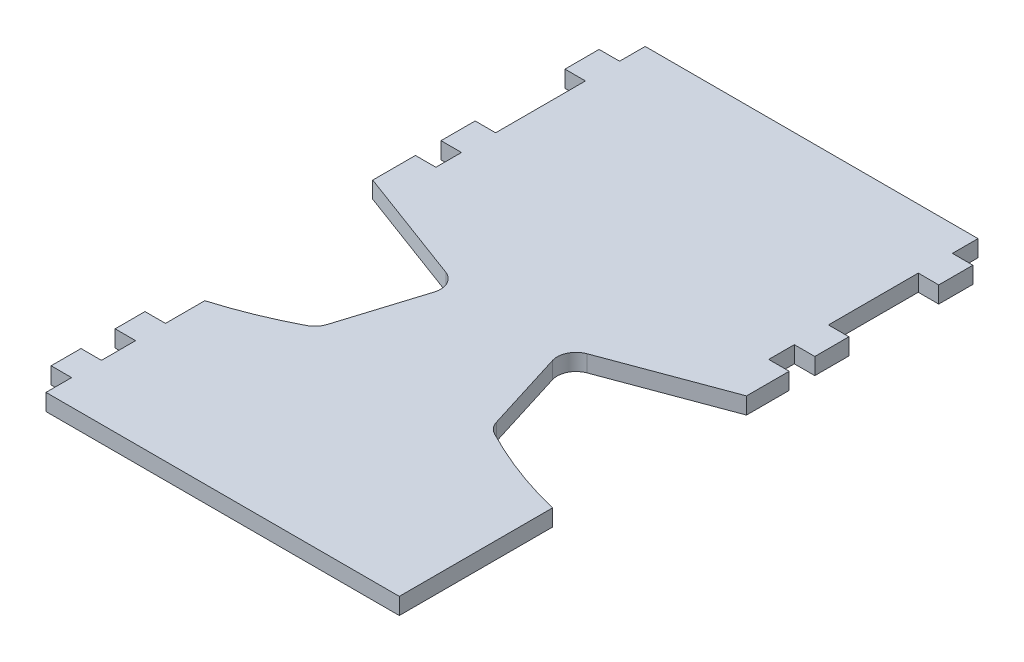
from build123d import *

# Parameters (mm, degrees)
BOSS_EXTRUDE1_DEPTH = 2.4765


with BuildPart() as part:
    # Sketch1 → Boss-Extrude1 (new, symmetric)
    with BuildSketch(Plane(origin=(0, 0, 0), x_dir=(1, 0, 0), z_dir=(0, 1, 0))):
        with BuildLine():
            Line((-49.53, 45.72), (49.53, 45.72))
            Line((49.53, 45.72), (49.53, 38.1))
            Line((49.53, 38.1), (55.626, 38.1))
            Line((55.626, 38.1), (55.626, 27.94))
            Line((55.626, 27.94), (49.53, 27.94))
            Line((49.53, 27.94), (49.53, 1.208143374))
            Line((49.53, 1.208143374), (55.626, 1.208143374))
            Line((55.626, 1.208143374), (55.626, -8.951856626))
            Line((55.626, -8.951856626), (49.53, -8.951856626))
            Line((49.53, -8.951856626), (49.53, -16.571856626))
            Line((49.53, -16.571856626), (55.626, -16.571856626))
            Line((55.626, -16.571856626), (55.626, -29.271856626))
            Line((55.626, -29.271856626), (21.019827136, -42.136821893))
            ThreePointArc((21.019827136, -42.136821893), (17.95098831, -44.911778638), (17.631953735, -49.036869377))
            Line((17.631953735, -49.036869377), (25.187729856, -73.287029113))
            ThreePointArc((25.187729856, -73.287029113), (26.234780075, -75.207903536), (27.939063878, -76.579577488))
            ThreePointArc((27.939063878, -76.579577488), (41.468907088, -82.632484358), (55.626, -87.022365809))
            Line((55.626, -87.022365809), (55.626, -132.617292876))
            Line((55.626, -132.617292876), (-49.53, -132.617292876))
            Line((-49.53, -132.617292876), (-49.53, -124.997292876))
            Line((-49.53, -124.997292876), (-55.626, -124.997292876))
            Line((-55.626, -124.997292876), (-55.626, -116.107292876))
            Line((-55.626, -116.107292876), (-49.53, -116.107292876))
            Line((-49.53, -116.107292876), (-49.53, -105.947292876))
            Line((-49.53, -105.947292876), (-55.626, -105.947292876))
            Line((-55.626, -105.947292876), (-55.626, -97.057292876))
            Line((-55.626, -97.057292876), (-49.53, -97.057292876))
            Line((-49.53, -97.057292876), (-49.53, -85.359826344))
            ThreePointArc((-49.53, -85.359826344), (-38.527111219, -81.479756652), (-27.939063878, -76.579577488))
            ThreePointArc((-27.939063878, -76.579577488), (-26.234780075, -75.207903536), (-25.187729856, -73.287029113))
            Line((-25.187729856, -73.287029113), (-17.631953735, -49.036869377))
            ThreePointArc((-17.631953735, -49.036869377), (-17.95098831, -44.911778638), (-21.019827136, -42.136821893))
            Line((-21.019827136, -42.136821893), (-55.626, -29.271856626))
            Line((-55.626, -29.271856626), (-55.626, -16.571856626))
            Line((-55.626, -16.571856626), (-49.53, -16.571856626))
            Line((-49.53, -16.571856626), (-49.53, -8.951856626))
            Line((-49.53, -8.951856626), (-55.626, -8.951856626))
            Line((-55.626, -8.951856626), (-55.626, 1.208143374))
            Line((-55.626, 1.208143374), (-49.53, 1.208143374))
            Line((-49.53, 1.208143374), (-49.53, 27.94))
            Line((-49.53, 27.94), (-55.626, 27.94))
            Line((-55.626, 27.94), (-55.626, 38.1))
            Line((-55.626, 38.1), (-49.53, 38.1))
            Line((-49.53, 38.1), (-49.53, 45.72))
        make_face()
    extrude(amount=BOSS_EXTRUDE1_DEPTH, both=True)


solid = part.part
